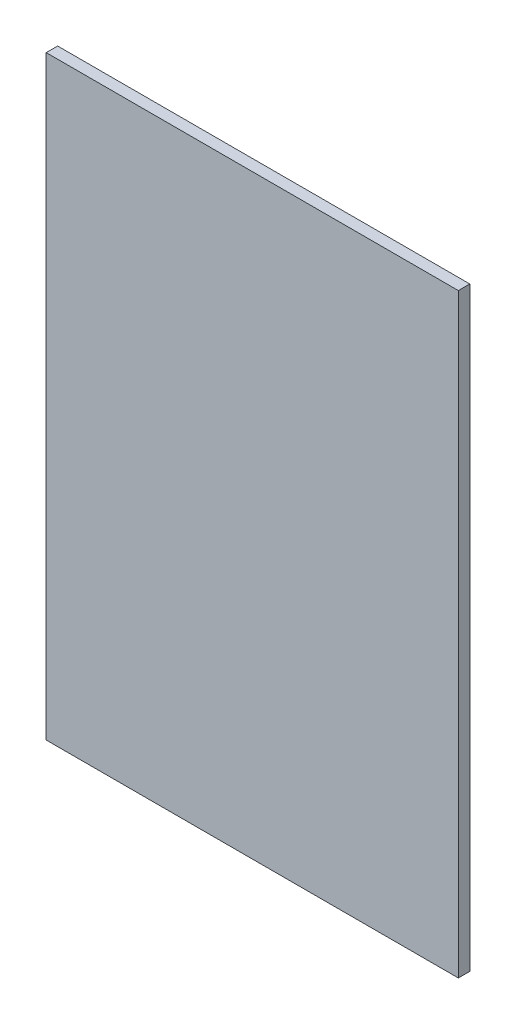
from build123d import *

# Parameters (mm, degrees)
ESQUISSE1_W        = 360
ESQUISSE1_H        = 520
BOSS_EXTRU_1_DEPTH = 10


with BuildPart() as part:
    # Esquisse1 → Boss.-Extru.1 (new body)
    with BuildSketch(Plane.XY):
        with Locations((64.538459462, 194.408501784)):
            Rectangle(ESQUISSE1_W, ESQUISSE1_H)
    extrude(amount=BOSS_EXTRU_1_DEPTH)


solid = part.part
